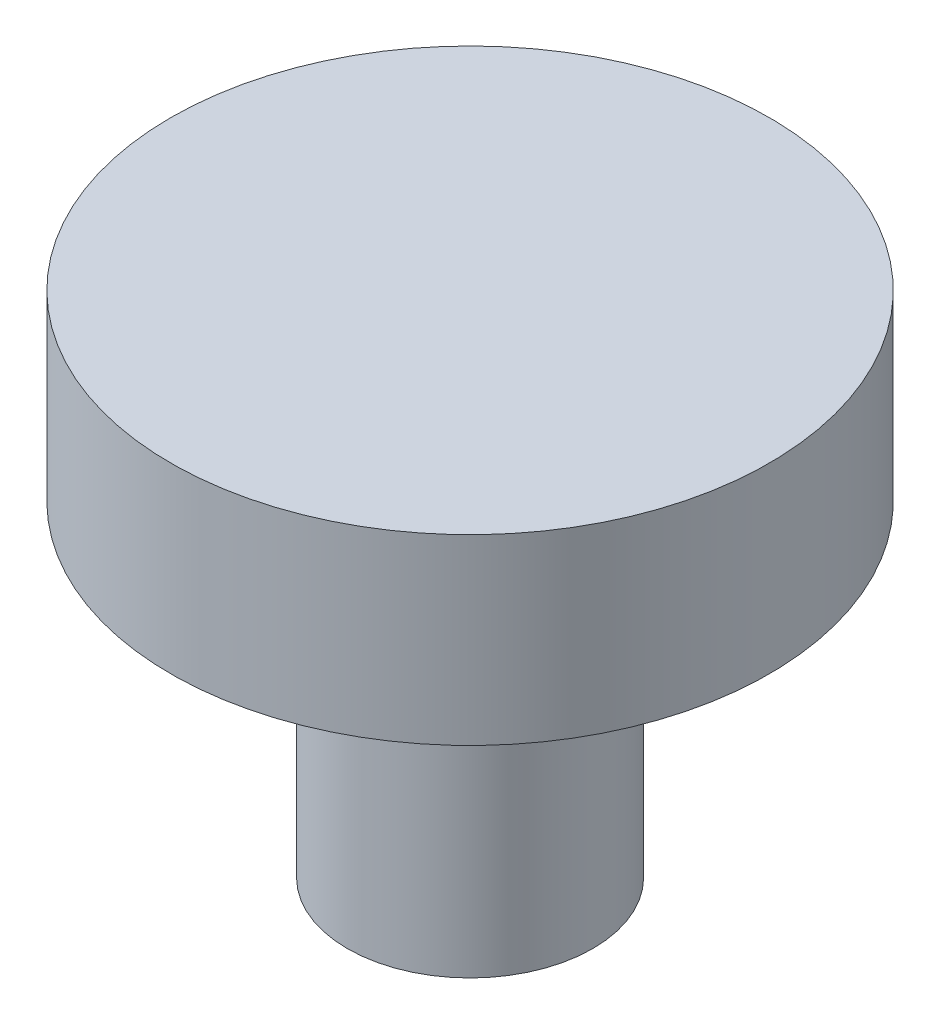
from build123d import *


with BuildPart() as part:
    # Sketch1 → Revolve1 (revolve)
    with BuildSketch(Plane.XY, mode=Mode.PRIVATE) as revolve1_sk:
        Polygon((0, 0), (0, -8.636), (2.0828, -8.636), (2.0828, -3.0988), (5.08, -3.0988), (5.08, 0), align=None)
    revolve(revolve1_sk.sketch.rotate(Axis((0, 29.88154274, 0), (0, -1, 0)), 180), axis=Axis((0, 29.88154274, 0), (0, -1, 0)))  # turned: the seam where the file's is


solid = part.part
